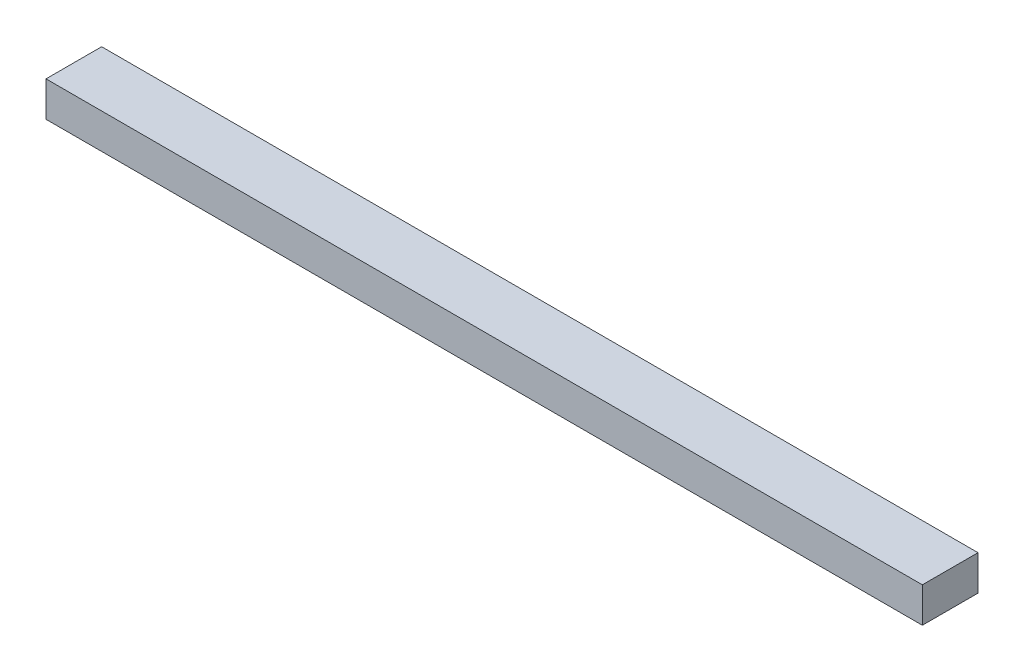
from build123d import *

# Parameters (mm, degrees)
SKETCH2_W           = 12.7
SKETCH2_H           = 8
BOSS_EXTRUDE1_DEPTH = 200


with BuildPart() as part:
    # Sketch2 → Boss-Extrude1 (new body)
    with BuildSketch(Plane(origin=(0, 0, 0), x_dir=(0, 0, -1), z_dir=(1, 0, 0))):
        Rectangle(SKETCH2_W, SKETCH2_H)
    extrude(amount=BOSS_EXTRUDE1_DEPTH)


solid = part.part
